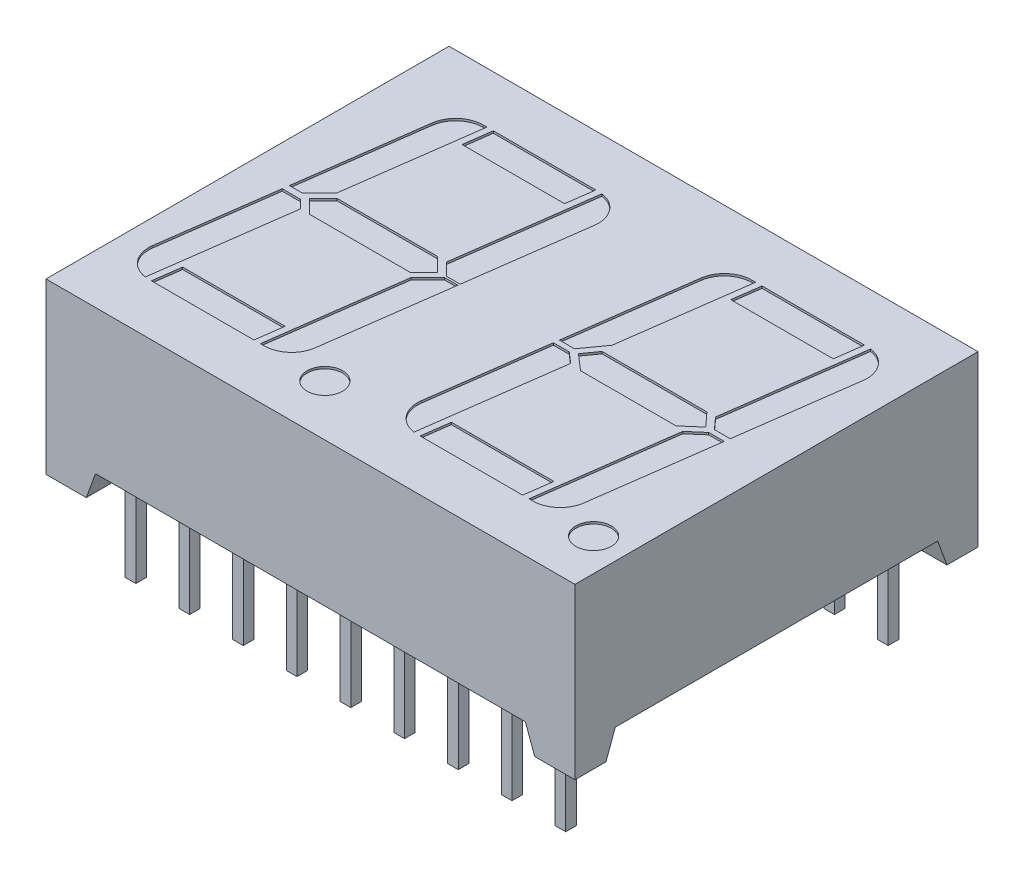
from build123d import *

# Parameters (mm, degrees)
SKETCH1_W          = 25
SKETCH1_H          = 19.05
EXTRUDE2_DEPTH     = 8
CUT_EXTRUDE2_DEPTH = 20.05
CUT_EXTRUDE3_DEPTH = 26
SKETCH5_W          = 0.5
SKETCH5_H          = 0.5
EXTRUDE3_DEPTH     = 1.2
SKETCH5_5_W        = 0.5
SKETCH5_5_H        = 0.5
EXTRUDE4_DEPTH     = 4
SKETCH1_4_R        = 0.84
CUT_EXTRUDE4_DEPTH = 0.1
SKETCH6_W          = 0.026582279
SKETCH6_H          = 0.025316456
CUT_EXTRUDE5_DEPTH = 0.01


with BuildPart() as part:
    # Sketch1 → Extrude2 (new body)
    with BuildSketch(Plane(origin=(0, 0, 0), x_dir=(1, 0, 0), z_dir=(0, 1, 0))):
        Rectangle(SKETCH1_W, SKETCH1_H)
    extrude(amount=-EXTRUDE2_DEPTH)

    # Sketch2 → Cut-Extrude2 (cut, through all)
    with BuildSketch(Plane.XY.offset(9.525)):
        Polygon((-10.596764281, -8), (-10.16, -6.8), (10.16, -6.8), (10.596764281, -8), align=None)
    extrude(amount=-CUT_EXTRUDE2_DEPTH, mode=Mode.SUBTRACT)

    # Sketch3 → Cut-Extrude3 (cut, through all)
    with BuildSketch(Plane(origin=(12.5, 0, 0), x_dir=(0, 0, -1), z_dir=(1, 0, 0))):
        Polygon((-8.056764281, -8), (-7.62, -6.8), (7.62, -6.8), (8.056764281, -8), align=None)
    extrude(amount=-CUT_EXTRUDE3_DEPTH, mode=Mode.SUBTRACT)

    # Sketch5 → Extrude3 (add)
    with BuildSketch(Plane.XZ.offset(8)):
        with Locations((-10.16, 7.62)):
            Rectangle(SKETCH5_W, SKETCH5_H)
        with Locations((-7.62, 7.62)):
            Rectangle(SKETCH5_W, SKETCH5_H)
        with Locations((-5.08, 7.62)):
            Rectangle(SKETCH5_W, SKETCH5_H)
        with Locations((-2.54, 7.62)):
            Rectangle(SKETCH5_W, SKETCH5_H)
        with Locations((0, 7.62)):
            Rectangle(SKETCH5_W, SKETCH5_H)
        with Locations((2.54, 7.62)):
            Rectangle(SKETCH5_W, SKETCH5_H)
        with Locations((7.62, 7.62)):
            Rectangle(SKETCH5_W, SKETCH5_H)
        with Locations((10.16, -7.62)):
            Rectangle(SKETCH5_W, SKETCH5_H)
        with Locations((7.62, -7.62)):
            Rectangle(SKETCH5_W, SKETCH5_H)
        with Locations((5.08, -7.62)):
            Rectangle(SKETCH5_W, SKETCH5_H)
        with Locations((2.54, -7.62)):
            Rectangle(SKETCH5_W, SKETCH5_H)
        with Locations((0, -7.62)):
            Rectangle(SKETCH5_W, SKETCH5_H)
        with Locations((-2.54, -7.62)):
            Rectangle(SKETCH5_W, SKETCH5_H)
        with Locations((-5.08, -7.62)):
            Rectangle(SKETCH5_W, SKETCH5_H)
        with Locations((-7.62, -7.62)):
            Rectangle(SKETCH5_W, SKETCH5_H)
        with Locations((-10.16, -7.62)):
            Rectangle(SKETCH5_W, SKETCH5_H)
        with Locations((5.08, 7.62)):
            Rectangle(SKETCH5_W, SKETCH5_H)
        with Locations((10.16, 7.62)):
            Rectangle(SKETCH5_W, SKETCH5_H)
    extrude(amount=-EXTRUDE3_DEPTH)

    # Sketch5_5 → Extrude4 (add)
    with BuildSketch(Plane.XZ.offset(8)):
        with Locations((-10.16, -7.62)):
            Rectangle(SKETCH5_5_W, SKETCH5_5_H)
        with Locations((-7.62, -7.62)):
            Rectangle(SKETCH5_5_W, SKETCH5_5_H)
        with Locations((-5.08, -7.62)):
            Rectangle(SKETCH5_5_W, SKETCH5_5_H)
        with Locations((-2.54, -7.62)):
            Rectangle(SKETCH5_5_W, SKETCH5_5_H)
        with Locations((0, -7.62)):
            Rectangle(SKETCH5_5_W, SKETCH5_5_H)
        with Locations((2.54, -7.62)):
            Rectangle(SKETCH5_5_W, SKETCH5_5_H)
        with Locations((5.08, -7.62)):
            Rectangle(SKETCH5_5_W, SKETCH5_5_H)
        with Locations((7.62, -7.62)):
            Rectangle(SKETCH5_5_W, SKETCH5_5_H)
        with Locations((10.16, -7.62)):
            Rectangle(SKETCH5_5_W, SKETCH5_5_H)
        with Locations((10.16, 7.62)):
            Rectangle(SKETCH5_5_W, SKETCH5_5_H)
        with Locations((7.62, 7.62)):
            Rectangle(SKETCH5_5_W, SKETCH5_5_H)
        with Locations((5.08, 7.62)):
            Rectangle(SKETCH5_5_W, SKETCH5_5_H)
        with Locations((2.54, 7.62)):
            Rectangle(SKETCH5_5_W, SKETCH5_5_H)
        with Locations((0, 7.62)):
            Rectangle(SKETCH5_5_W, SKETCH5_5_H)
        with Locations((-2.54, 7.62)):
            Rectangle(SKETCH5_5_W, SKETCH5_5_H)
        with Locations((-5.08, 7.62)):
            Rectangle(SKETCH5_5_W, SKETCH5_5_H)
        with Locations((-7.62, 7.62)):
            Rectangle(SKETCH5_5_W, SKETCH5_5_H)
        with Locations((-10.16, 7.62)):
            Rectangle(SKETCH5_5_W, SKETCH5_5_H)
    extrude(amount=EXTRUDE4_DEPTH)

    # Sketch1_4 → Cut-Extrude4 (cut)
    with BuildSketch(Plane(origin=(0, 0, 0), x_dir=(1, 0, 0), z_dir=(0, 1, 0))):
        with BuildLine():
            Line((-3.93123169, -0.847816945), (-4.785666695, -7.11))
            Line((-4.785666695, -7.11), (-4.608289973, -7.11))
            ThreePointArc((-4.608289973, -7.11), (-3.753442858, -6.789406152), (-3.320224553, -5.985748325))
            Line((-3.320224553, -5.985748325), (-2.510329488, -0.05))
            Line((-2.510329488, -0.05), (-3.139803689, -0.05))
            Line((-3.139803689, -0.05), (-3.93123169, -0.847816945))
        make_face()
        Polygon((-5.088446347, -7.11), (-4.911069625, -5.81), (-9.755544062, -5.81), (-9.932920784, -7.11), align=None)
        Polygon((-4.157567593, -0.65), (-3.512772814, 0), (-4.168020055, 0.65), (-8.923571081, 0.65), (-9.56836586, 0), (-8.913118619, -0.65), align=None)
        with BuildLine():
            Line((-10.234072039, -7.09806542), (-9.352465365, -0.63674028))
            Line((-9.352465365, -0.63674028), (-9.742327675, -0.25))
            Line((-9.742327675, -0.25), (-10.611742276, -0.25))
            Line((-10.611742276, -0.25), (-11.346389134, -5.634251675))
            ThreePointArc((-11.346389134, -5.634251675), (-11.093396339, -6.596526961), (-10.234072039, -7.09806542))
        make_face()
        with BuildLine():
            Line((-3.728673309, 0.63674028), (-3.137196463, 0.05))
            Line((-3.137196463, 0.05), (-2.496685125, 0.05))
            Line((-2.496685125, 0.05), (-1.73474954, 5.634251675))
            ThreePointArc((-1.73474954, 5.634251675), (-1.987742335, 6.596526961), (-2.847066635, 7.09806542))
            Line((-2.847066635, 7.09806542), (-3.728673309, 0.63674028))
        make_face()
        with BuildLine():
            Line((-10.570809186, 0.05), (-9.941334985, 0.05))
            Line((-9.941334985, 0.05), (-9.149906984, 0.847816945))
            Line((-9.149906984, 0.847816945), (-8.295471979, 7.11))
            Line((-8.295471979, 7.11), (-8.472848701, 7.11))
            ThreePointArc((-8.472848701, 7.11), (-9.327695816, 6.789406152), (-9.760914121, 5.985748325))
            Line((-9.760914121, 5.985748325), (-10.570809186, 0.05))
        make_face()
        Polygon((-8.170069049, 5.81), (-3.325594612, 5.81), (-3.14821789, 7.11), (-7.992692327, 7.11), align=None)
        Polygon((7.789032999, -5.81), (2.944558562, -5.81), (2.76718184, -7.11), (7.611656276, -7.11), align=None)
        with BuildLine():
            Line((2.466030585, -7.09806542), (3.35486626, -0.583758689))
            Line((3.35486626, -0.583758689), (2.851674798, -0.145974081))
            Line((2.851674798, -0.145974081), (2.102554022, -0.145974081))
            Line((2.102554022, -0.145974081), (1.35371349, -5.634251675))
            ThreePointArc((1.35371349, -5.634251675), (1.606706284, -6.596526961), (2.466030585, -7.09806542))
        make_face()
        with BuildLine():
            Line((8.787000175, -0.714947122), (7.914435929, -7.11))
            Line((7.914435929, -7.11), (8.091812651, -7.11))
            ThreePointArc((8.091812651, -7.11), (8.946659765, -6.789406152), (9.379878071, -5.985748325))
            Line((9.379878071, -5.985748325), (10.176678083, -0.145974081))
            Line((10.176678083, -0.145974081), (9.444259288, -0.145974081))
            Line((9.444259288, -0.145974081), (8.787000175, -0.714947122))
        make_face()
        Polygon((3.888061955, -0.65), (8.403661518, -0.65), (9.154520334, 0), (8.563273677, 0.65), (3.608753705, 0.65), (3.140949231, 0), align=None)
        with BuildLine():
            Line((2.136936451, 0.106015903), (2.84763139, 0.106015903))
            Line((2.84763139, 0.106015903), (3.589658211, 1.137039464))
            Line((3.589658211, 1.137039464), (4.404630645, 7.11))
            Line((4.404630645, 7.11), (4.227253922, 7.11))
            ThreePointArc((4.227253922, 7.11), (3.372406808, 6.789406152), (2.939188502, 5.985748325))
            Line((2.939188502, 5.985748325), (2.136936451, 0.106015903))
        make_face()
        with BuildLine():
            Line((8.972661757, 0.64577289), (9.46363024, 0.106015903))
            Line((9.46363024, 0.106015903), (10.211060512, 0.106015903))
            Line((10.211060512, 0.106015903), (10.965353084, 5.634251675))
            ThreePointArc((10.965353084, 5.634251675), (10.712360289, 6.59652696), (9.853035989, 7.09806542))
            Line((9.853035989, 7.09806542), (8.972661757, 0.64577289))
        make_face()
        Polygon((4.707410297, 7.11), (4.530033575, 5.81), (9.374508011, 5.81), (9.551884734, 7.11), align=None)
        with Locations(Location((-1.73474954, -7.11, 0), (0, 0, 90))):  # turned: the seam where the file's is
            Circle(SKETCH1_4_R)
        with Locations(Location((10.965353084, -7.11, 0), (0, 0, 90))):  # turned: the seam where the file's is
            Circle(SKETCH1_4_R)
    extrude(amount=-CUT_EXTRUDE4_DEPTH, mode=Mode.SUBTRACT)

    # Sketch6 → Cut-Extrude5 (cut)
    with BuildSketch(Plane.XZ.offset(6.8)):
        Polygon((-10.77177609, 0.348226109), (-10.846459634, 0.371683388), (-10.846459634, 0.396426268), (-10.7961234, 0.412842407), (-10.846459634, 0.428368514), (-10.846459634, 0.454100318), (-10.77177609, 0.477340033), (-10.77177609, 0.452162027), (-10.823259476, 0.439167565), (-10.77177609, 0.422751426), (-10.77177609, 0.401252217), (-10.823259476, 0.38493497), (-10.77177609, 0.372118514), align=None)
        Polygon((-10.77177609, 0.214048894), (-10.846459634, 0.237506173), (-10.846459634, 0.262249052), (-10.7961234, 0.278665192), (-10.846459634, 0.294191299), (-10.846459634, 0.319923103), (-10.77177609, 0.343162818), (-10.77177609, 0.317984812), (-10.823259476, 0.30499035), (-10.77177609, 0.288574211), (-10.77177609, 0.267075002), (-10.823259476, 0.250757755), (-10.77177609, 0.237941299), align=None)
        Polygon((-10.77177609, 0.079871679), (-10.846459634, 0.103328957), (-10.846459634, 0.128071837), (-10.7961234, 0.144487976), (-10.846459634, 0.160014084), (-10.846459634, 0.185745888), (-10.77177609, 0.208985603), (-10.77177609, 0.183807597), (-10.823259476, 0.170813135), (-10.77177609, 0.154396995), (-10.77177609, 0.132897787), (-10.823259476, 0.11658054), (-10.77177609, 0.103764084), align=None)
        with Locations((-10.833168495, 0.052023578)):
            Rectangle(SKETCH6_W, SKETCH6_H)
        with BuildLine():
            add(Edge.make_bspline(
                [(-10.815288748, -0.064432118), (-10.816510881, -0.06439562), (-10.818910744, -0.06432395), (-10.822418432, -0.063714363), (-10.825742736, -0.062720396), (-10.828906881, -0.061348057), (-10.83187637, -0.059554601), (-10.834679261, -0.05737133), (-10.837283806, -0.054782447), (-10.83972018, -0.051835643), (-10.841902292, -0.0485387), (-10.843808325, -0.044940986), (-10.845402996, -0.041060959), (-10.846742062, -0.036912748), (-10.847730495, -0.032466201), (-10.848454482, -0.027748703), (-10.8489278, -0.022755275), (-10.848969768, -0.019331698), (-10.848991279, -0.017576897)],
                knots=[0, 0, 0, 0, 0.907312236, 1.78165839, 2.635367075, 3.479697475, 4.336364812, 5.205276731, 6.11257575, 7.058770404, 8.040786331, 9.044147278, 10.078219212, 11.153049307, 12.278104542, 13.457648573, 14.696882856, 16, 16, 16, 16], degree=3))
            add(Edge.make_bspline(
                [(-10.848991279, -0.017576897), (-10.848967208, -0.015558642), (-10.848920583, -0.011649459), (-10.848491984, -0.005985934), (-10.847845844, -0.000717897), (-10.846879303, 0.004177818), (-10.845678538, 0.008782417), (-10.844387246, 0.013215685), (-10.84292283, 0.017496997), (-10.841822673, 0.020270086), (-10.841277672, 0.021643831)],
                knots=[0, 0, 0, 0, 1.203215828, 2.33052265, 3.384689099, 4.366106119, 5.303329643, 6.221311756, 7.118865988, 8, 8, 8, 8], degree=3))
            Line((-10.841277672, 0.021643831), (-10.81734571, 0.021643831))
            Line((-10.81734571, 0.021643831), (-10.81734571, 0.01879573))
            add(Edge.make_bspline(
                [(-10.81734571, 0.01879573), (-10.818427165, 0.017430416), (-10.820583726, 0.014707803), (-10.823346331, 0.01027457), (-10.825748494, 0.005626924), (-10.827722496, 0.000781453), (-10.82930882, -0.004115391), (-10.830402347, -0.008990769), (-10.831149696, -0.013756356), (-10.831230203, -0.016914926), (-10.83126976, -0.018466929)],
                knots=[0, 0, 0, 0, 1.030622468, 2.055194264, 3.087043286, 4.125157485, 5.149848264, 6.130935704, 7.081611712, 8, 8, 8, 8], degree=3))
            add(Edge.make_bspline(
                [(-10.83126976, -0.018466929), (-10.831268866, -0.018895707), (-10.831266951, -0.019813689), (-10.831138108, -0.021281726), (-10.831044944, -0.022940325), (-10.830835727, -0.024719191), (-10.830617144, -0.026510009), (-10.830236823, -0.028164669), (-10.829874985, -0.029668308), (-10.829506807, -0.03057479), (-10.829331469, -0.031006486)],
                knots=[0, 0, 0, 0, 0.806378557, 1.726393851, 2.771014456, 3.931269413, 5.096090628, 6.161710732, 7.124547685, 8, 8, 8, 8], degree=3))
            add(Edge.make_bspline(
                [(-10.829331469, -0.031006486), (-10.829103646, -0.031486272), (-10.828655923, -0.032429156), (-10.827838317, -0.033724075), (-10.826967015, -0.034906747), (-10.826001596, -0.035968208), (-10.824823687, -0.036818475), (-10.823422831, -0.037446676), (-10.821772531, -0.03778977), (-10.82059752, -0.037829064), (-10.819976248, -0.03784984)],
                knots=[0, 0, 0, 0, 1.024407818, 2.013179384, 2.949802342, 3.859052226, 4.77034807, 5.732977883, 6.801339628, 8, 8, 8, 8], degree=3))
            add(Edge.make_bspline(
                [(-10.819976248, -0.03784984), (-10.819430352, -0.037818398), (-10.818356959, -0.037756575), (-10.816828963, -0.037174783), (-10.815407086, -0.036291885), (-10.814146371, -0.035004862), (-10.812988932, -0.033410786), (-10.812018635, -0.031455049), (-10.811138562, -0.02920207), (-10.810721293, -0.027557611), (-10.810502355, -0.026694777)],
                knots=[0, 0, 0, 0, 0.825212765, 1.622611382, 2.449701629, 3.348069183, 4.336544339, 5.428209675, 6.6506027, 8, 8, 8, 8], degree=3))
            add(Edge.make_bspline(
                [(-10.810502355, -0.026694777), (-10.810054615, -0.02472605), (-10.809137425, -0.020693142), (-10.807990318, -0.014545033), (-10.806724245, -0.008414805), (-10.805514704, -0.004456093), (-10.804924824, -0.002525473)],
                knots=[0, 0, 0, 0, 0.976104583, 1.999535498, 3.024395274, 4, 4, 4, 4], degree=3))
            add(Edge.make_bspline(
                [(-10.804924824, -0.002525473), (-10.804571831, -0.001486957), (-10.803884698, 0.000534611), (-10.802723073, 0.003426155), (-10.801453121, 0.006087268), (-10.800097989, 0.008527378), (-10.798623991, 0.0107267), (-10.797090602, 0.01272189), (-10.795436765, 0.014465416), (-10.793704845, 0.0160131), (-10.791852843, 0.017336414), (-10.789908706, 0.018491164), (-10.787848241, 0.0194668), (-10.785686952, 0.020275683), (-10.783408083, 0.020892756), (-10.78103121, 0.021314012), (-10.77854785, 0.021612401), (-10.776853497, 0.021633212), (-10.775988906, 0.021643831)],
                knots=[0, 0, 0, 0, 1.287286806, 2.505824366, 3.654938963, 4.74627059, 5.778586806, 6.75996495, 7.696030012, 8.595059759, 9.482019644, 10.363222407, 11.245851011, 12.154256429, 13.068444161, 14.012503255, 14.985824751, 16, 16, 16, 16], degree=3))
            add(Edge.make_bspline(
                [(-10.775988906, 0.021643831), (-10.774832761, 0.021606529), (-10.772557489, 0.02153312), (-10.769228445, 0.020931691), (-10.766079708, 0.019905101), (-10.763076245, 0.018519037), (-10.760263159, 0.016690409), (-10.757584612, 0.014505615), (-10.75511302, 0.011881567), (-10.752812686, 0.008904446), (-10.750733288, 0.005617062), (-10.748902731, 0.002078078), (-10.74736608, -0.001691211), (-10.746092186, -0.005676758), (-10.745137515, -0.009895227), (-10.744418583, -0.014332459), (-10.744005402, -0.019006248), (-10.743954152, -0.02219767), (-10.743927988, -0.023826897)],
                knots=[0, 0, 0, 0, 0.894990994, 1.761326291, 2.609044902, 3.454222546, 4.315366365, 5.200560057, 6.125081389, 7.100429509, 8.110379559, 9.133447974, 10.182136699, 11.259192205, 12.370181258, 13.528580438, 14.738335141, 16, 16, 16, 16], degree=3))
            add(Edge.make_bspline(
                [(-10.743927988, -0.023826897), (-10.74395018, -0.025495584), (-10.743994525, -0.028830129), (-10.744372503, -0.033811571), (-10.744927731, -0.038772073), (-10.745769437, -0.043635904), (-10.746745854, -0.048326459), (-10.747841649, -0.052739695), (-10.749079613, -0.056819155), (-10.750033958, -0.059392819), (-10.750494444, -0.06063465)],
                knots=[0, 0, 0, 0, 1.065403572, 2.129000689, 3.188532477, 4.251604565, 5.279552602, 6.247508681, 7.154397237, 8, 8, 8, 8], degree=3))
            Line((-10.750494444, -0.06063465), (-10.773041912, -0.06063465))
            Line((-10.773041912, -0.06063465), (-10.773041912, -0.057806327))
            add(Edge.make_bspline(
                [(-10.773041912, -0.057806327), (-10.772241566, -0.056733423), (-10.770604836, -0.054539304), (-10.768521163, -0.050879667), (-10.766563298, -0.046921432), (-10.764879139, -0.042642601), (-10.763419658, -0.038183574), (-10.762400492, -0.033600615), (-10.761758682, -0.028974451), (-10.761685907, -0.02587274), (-10.761649507, -0.024321359)],
                knots=[0, 0, 0, 0, 0.892283326, 1.824742884, 2.804416662, 3.836872171, 4.8899239, 5.931447339, 6.965372909, 8, 8, 8, 8], degree=3))
            add(Edge.make_bspline(
                [(-10.761649507, -0.024321359), (-10.76167096, -0.023225691), (-10.761713862, -0.021034475), (-10.762104546, -0.017766266), (-10.76273544, -0.014524205), (-10.763554722, -0.012483683), (-10.76396359, -0.011465346)],
                knots=[0, 0, 0, 0, 0.999146175, 1.998183711, 3.000980573, 4, 4, 4, 4], degree=3))
            add(Edge.make_bspline(
                [(-10.76396359, -0.011465346), (-10.764165056, -0.011031843), (-10.764567856, -0.010165126), (-10.765340419, -0.008958481), (-10.76626923, -0.007853812), (-10.767321223, -0.006861735), (-10.768477596, -0.005993337), (-10.769752422, -0.005377986), (-10.771115337, -0.005002113), (-10.772050568, -0.004959955), (-10.772527672, -0.004938448)],
                knots=[0, 0, 0, 0, 1.00524851, 2.009826503, 3.004679593, 4.035271301, 5.048246368, 6.034938417, 6.997532266, 8, 8, 8, 8], degree=3))
            add(Edge.make_bspline(
                [(-10.772527672, -0.004938448), (-10.773165837, -0.004972886), (-10.774385313, -0.005038694), (-10.776101109, -0.005645278), (-10.777579543, -0.006630112), (-10.778574463, -0.007790716), (-10.779271901, -0.008907846), (-10.779782411, -0.009943506), (-10.78026577, -0.011152733), (-10.780763239, -0.01252398), (-10.781254426, -0.014060307), (-10.781729973, -0.015768864), (-10.782179269, -0.017651581), (-10.782465459, -0.018967456), (-10.782614697, -0.019653637)],
                knots=[0, 0, 0, 0, 1.173816843, 2.243057204, 3.312297565, 4.415174738, 5.03266065, 5.73970059, 6.541434878, 7.433956553, 8.430083051, 9.515931566, 10.70464786, 12, 12, 12, 12], degree=3))
            add(Edge.make_bspline(
                [(-10.782614697, -0.019653637), (-10.782990759, -0.021486427), (-10.783729636, -0.025087453), (-10.784833125, -0.030488636), (-10.786108094, -0.03599141), (-10.787256897, -0.039656736), (-10.787855995, -0.041568194)],
                knots=[0, 0, 0, 0, 0.995744513, 1.956417928, 2.934277412, 4, 4, 4, 4], degree=3))
            add(Edge.make_bspline(
                [(-10.787855995, -0.041568194), (-10.788175239, -0.042514749), (-10.788799731, -0.044366362), (-10.789886014, -0.047006992), (-10.791059997, -0.049454051), (-10.792301528, -0.051721084), (-10.793645494, -0.053795054), (-10.795068141, -0.055689736), (-10.79659505, -0.057373554), (-10.798208277, -0.05887112), (-10.799918378, -0.06019028), (-10.80175745, -0.061322578), (-10.803706253, -0.062294806), (-10.805792453, -0.063064411), (-10.80798704, -0.063682431), (-10.810318408, -0.064105528), (-10.812762784, -0.064399512), (-10.814437361, -0.064421128), (-10.815288748, -0.064432118)],
                knots=[0, 0, 0, 0, 1.237467875, 2.420686895, 3.535046182, 4.599015201, 5.620884487, 6.594603852, 7.531477383, 8.433220087, 9.318759595, 10.202828513, 11.105163009, 12.01247538, 12.953896178, 13.926381251, 14.945733412, 16, 16, 16, 16], degree=3))
        make_face()
        with BuildLine():
            Line((-10.846459634, -0.156837182), (-10.846459634, -0.132786549))
            Line((-10.846459634, -0.132786549), (-10.838627355, -0.132786549))
            add(Edge.make_bspline(
                [(-10.838627355, -0.132786549), (-10.839435914, -0.13169324), (-10.840994802, -0.129585357), (-10.84307502, -0.126412332), (-10.844850286, -0.123386241), (-10.846409506, -0.120472751), (-10.847584892, -0.117450547), (-10.848412958, -0.114219033), (-10.848912731, -0.110716208), (-10.848964515, -0.108289314), (-10.848991279, -0.107034967)],
                knots=[0, 0, 0, 0, 1.150872466, 2.218865267, 3.209461834, 4.120482262, 5.012764827, 5.946708227, 6.938749913, 8, 8, 8, 8], degree=3))
            add(Edge.make_bspline(
                [(-10.848991279, -0.107034967), (-10.84896856, -0.106018615), (-10.84892432, -0.104039484), (-10.848579442, -0.101162244), (-10.848041791, -0.098454616), (-10.8472342, -0.095939576), (-10.846268397, -0.093575587), (-10.844988439, -0.091438037), (-10.843558265, -0.089434436), (-10.841851219, -0.087652763), (-10.839953486, -0.086037142), (-10.837821025, -0.084654592), (-10.8354881, -0.083476881), (-10.832936246, -0.082535783), (-10.830177943, -0.081780694), (-10.827198695, -0.081256761), (-10.824011568, -0.080936169), (-10.821816437, -0.080904229), (-10.820688273, -0.080887815)],
                knots=[0, 0, 0, 0, 1.109008058, 2.159558935, 3.158726032, 4.116861086, 5.039058877, 5.938775559, 6.82970133, 7.720510853, 8.624361809, 9.544451588, 10.487360536, 11.471068125, 12.508000841, 13.604731202, 14.768976642, 16, 16, 16, 16], degree=3))
            Line((-10.820688273, -0.080887815), (-10.77177609, -0.080887815))
            Line((-10.77177609, -0.080887815), (-10.77177609, -0.104938448))
            Line((-10.77177609, -0.104938448), (-10.809355203, -0.104938448))
            add(Edge.make_bspline(
                [(-10.809355203, -0.104938448), (-10.810271674, -0.104940083), (-10.81202589, -0.104943214), (-10.814531697, -0.105025553), (-10.816799869, -0.105146453), (-10.818841898, -0.105285158), (-10.820688648, -0.105538175), (-10.82235481, -0.105915883), (-10.823874411, -0.106386709), (-10.824781113, -0.106851028), (-10.825217545, -0.107074524)],
                knots=[0, 0, 0, 0, 1.361401701, 2.605856924, 3.723918663, 4.735739235, 5.645738665, 6.489217889, 7.27279937, 8, 8, 8, 8], degree=3))
            add(Edge.make_bspline(
                [(-10.825217545, -0.107074524), (-10.82561626, -0.10730453), (-10.826400099, -0.107756704), (-10.827406278, -0.108676994), (-10.828250545, -0.109755736), (-10.828906574, -0.11103334), (-10.829405522, -0.112519888), (-10.829745759, -0.114247819), (-10.829961261, -0.116233181), (-10.829989169, -0.117642199), (-10.830003938, -0.118387815)],
                knots=[0, 0, 0, 0, 0.849138082, 1.669332372, 2.503455908, 3.370611167, 4.311442699, 5.394692208, 6.621337967, 8, 8, 8, 8], degree=3))
            add(Edge.make_bspline(
                [(-10.830003938, -0.118387815), (-10.829986581, -0.118929099), (-10.829950893, -0.120042016), (-10.829718447, -0.121753329), (-10.829361773, -0.123549906), (-10.828701917, -0.126064488), (-10.827515738, -0.129231116), (-10.82616133, -0.131590417), (-10.825474665, -0.132786549)],
                knots=[0, 0, 0, 0, 0.638127216, 1.312033637, 2.033062677, 2.79661882, 4.375931797, 6, 6, 6, 6], degree=3))
            Line((-10.825474665, -0.132786549), (-10.77177609, -0.132786549))
            Line((-10.77177609, -0.132786549), (-10.77177609, -0.156837182))
            Line((-10.77177609, -0.156837182), (-10.846459634, -0.156837182))
        make_face()
        with BuildLine():
            Line((-10.846459634, -0.254305536), (-10.846459634, -0.230254903))
            Line((-10.846459634, -0.230254903), (-10.80888052, -0.230254903))
            add(Edge.make_bspline(
                [(-10.80888052, -0.230254903), (-10.807350477, -0.230230389), (-10.804299452, -0.230181505), (-10.800537041, -0.229899381), (-10.797694717, -0.229520859), (-10.795856836, -0.229151204), (-10.794308696, -0.228719504), (-10.793422937, -0.228307224), (-10.793018178, -0.228118827)],
                knots=[0, 0, 0, 0, 1.709124929, 3.408128882, 4.211124727, 4.91016634, 5.501986363, 6, 6, 6, 6], degree=3))
            add(Edge.make_bspline(
                [(-10.793018178, -0.228118827), (-10.792620125, -0.227874365), (-10.791839685, -0.227395061), (-10.790826672, -0.226457737), (-10.789997831, -0.225363851), (-10.78931628, -0.224093081), (-10.7888457, -0.222601884), (-10.78845247, -0.220885144), (-10.788285561, -0.218898526), (-10.788250401, -0.217491256), (-10.788231786, -0.216746201)],
                knots=[0, 0, 0, 0, 0.86006424, 1.686277094, 2.52783008, 3.38194165, 4.331801563, 5.402842185, 6.624978739, 8, 8, 8, 8], degree=3))
            add(Edge.make_bspline(
                [(-10.788231786, -0.216746201), (-10.788288523, -0.215614379), (-10.788404376, -0.213303285), (-10.789115884, -0.210441091), (-10.789934843, -0.208110487), (-10.790693674, -0.206257963), (-10.791665116, -0.204349332), (-10.792386938, -0.20306992), (-10.792761058, -0.202406802)],
                knots=[0, 0, 0, 0, 1.338371478, 2.732853438, 3.468019217, 4.261884641, 5.099136535, 6, 6, 6, 6], degree=3))
            Line((-10.792761058, -0.202406802), (-10.846459634, -0.202406802))
            Line((-10.846459634, -0.202406802), (-10.846459634, -0.178356169))
            Line((-10.846459634, -0.178356169), (-10.77177609, -0.178356169))
            Line((-10.77177609, -0.178356169), (-10.77177609, -0.202406802))
            Line((-10.77177609, -0.202406802), (-10.779608368, -0.202406802))
            add(Edge.make_bspline(
                [(-10.779608368, -0.202406802), (-10.778802216, -0.203464209), (-10.777232994, -0.205522513), (-10.775192574, -0.208701751), (-10.773393804, -0.211785649), (-10.771880988, -0.214838659), (-10.770674213, -0.217953614), (-10.769863224, -0.221216372), (-10.769319421, -0.224632778), (-10.769269727, -0.226969493), (-10.769244444, -0.228158384)],
                knots=[0, 0, 0, 0, 1.126119141, 2.192057864, 3.198061997, 4.149848529, 5.076251285, 6.021887753, 6.99356175, 8, 8, 8, 8], degree=3))
            add(Edge.make_bspline(
                [(-10.769244444, -0.228158384), (-10.769269833, -0.229154656), (-10.769319397, -0.231099555), (-10.769629106, -0.233934315), (-10.770179771, -0.236605736), (-10.7709776, -0.23909801), (-10.771963212, -0.24144063), (-10.773194727, -0.243602574), (-10.77465315, -0.245594645), (-10.776314153, -0.247423046), (-10.778203879, -0.249053864), (-10.780321143, -0.2504709), (-10.78266424, -0.251650882), (-10.785224549, -0.252621594), (-10.787989658, -0.253396017), (-10.790985624, -0.253911148), (-10.794189802, -0.254264932), (-10.796405846, -0.254291731), (-10.79754745, -0.254305536)],
                knots=[0, 0, 0, 0, 1.08848837, 2.124922927, 3.110950502, 4.063144162, 4.979605775, 5.882838355, 6.774625441, 7.671951181, 8.57587277, 9.494821853, 10.448322275, 11.435533005, 12.482327682, 13.580118324, 14.753386918, 16, 16, 16, 16], degree=3))
            Line((-10.79754745, -0.254305536), (-10.846459634, -0.254305536))
        make_face()
        Polygon((-10.846459634, -0.349242245), (-10.846459634, -0.277090346), (-10.746459634, -0.277090346), (-10.746459634, -0.302406802), (-10.827472292, -0.302406802), (-10.827472292, -0.349242245), align=None)
        Polygon((-10.846459634, -0.436584017), (-10.846459634, -0.364432118), (-10.746459634, -0.364432118), (-10.746459634, -0.436584017), (-10.765446976, -0.436584017), (-10.765446976, -0.389748574), (-10.783168495, -0.389748574), (-10.783168495, -0.432786549), (-10.802155836, -0.432786549), (-10.802155836, -0.389748574), (-10.827472292, -0.389748574), (-10.827472292, -0.436584017), align=None)
        with BuildLine():
            add(Edge.make_bspline(
                [(-10.796558526, -0.553039713), (-10.797706215, -0.553020398), (-10.799979101, -0.552982146), (-10.803343908, -0.552686955), (-10.806609583, -0.552160929), (-10.809793832, -0.551481748), (-10.812872759, -0.550559242), (-10.815880337, -0.549477528), (-10.81878583, -0.548167882), (-10.821587265, -0.54666303), (-10.824259367, -0.545013558), (-10.826779576, -0.543238809), (-10.829162794, -0.541393029), (-10.831357688, -0.539403717), (-10.833399707, -0.537324535), (-10.835290522, -0.535149007), (-10.836993952, -0.532843942), (-10.838016837, -0.53123678), (-10.838528463, -0.53043291)],
                knots=[0, 0, 0, 0, 1.105570398, 2.18947457, 3.250358341, 4.290584537, 5.323553275, 6.344225964, 7.367641686, 8.3905646, 9.405808457, 10.390761353, 11.358902336, 12.307789878, 13.241960776, 14.165076779, 15.082208636, 16, 16, 16, 16], degree=3))
            add(Edge.make_bspline(
                [(-10.838528463, -0.53043291), (-10.839240602, -0.529193681), (-10.840668515, -0.526708902), (-10.842337105, -0.522725067), (-10.843741221, -0.518599585), (-10.844795646, -0.514249198), (-10.84552269, -0.509602189), (-10.846083496, -0.50460078), (-10.846385256, -0.49919319), (-10.846434276, -0.495458295), (-10.846459634, -0.493526264)],
                knots=[0, 0, 0, 0, 0.896288622, 1.797150563, 2.705281913, 3.629615989, 4.602417572, 5.655716007, 6.787320449, 8, 8, 8, 8], degree=3))
            Line((-10.846459634, -0.493526264), (-10.846459634, -0.458103005))
            Line((-10.846459634, -0.458103005), (-10.746459634, -0.458103005))
            Line((-10.746459634, -0.458103005), (-10.746459634, -0.494534967))
            add(Edge.make_bspline(
                [(-10.746459634, -0.494534967), (-10.746476245, -0.496513698), (-10.746508285, -0.500330427), (-10.746925876, -0.505847266), (-10.7475227, -0.510952474), (-10.748447571, -0.515637822), (-10.749562916, -0.519937826), (-10.750922044, -0.523863302), (-10.752420752, -0.527475076), (-10.753694445, -0.529653918), (-10.754311691, -0.530709808)],
                knots=[0, 0, 0, 0, 1.267175336, 2.444223962, 3.542125549, 4.557526608, 5.500936977, 6.385043188, 7.217374394, 8, 8, 8, 8], degree=3))
            add(Edge.make_bspline(
                [(-10.754311691, -0.530709808), (-10.754848231, -0.531560762), (-10.755915145, -0.533252886), (-10.757696997, -0.535654101), (-10.759653074, -0.537883528), (-10.761704893, -0.540012031), (-10.76390778, -0.541991849), (-10.766246487, -0.543835048), (-10.768724581, -0.545538865), (-10.77133405, -0.547096829), (-10.774064102, -0.548517644), (-10.776937161, -0.54970695), (-10.779915691, -0.550756299), (-10.783024653, -0.551561835), (-10.78623249, -0.552259749), (-10.789573834, -0.552694484), (-10.793026322, -0.552981095), (-10.795371212, -0.553020009), (-10.796558526, -0.553039713)],
                knots=[0, 0, 0, 0, 0.964065863, 1.917049184, 2.86229036, 3.805247319, 4.749389377, 5.698846072, 6.657678277, 7.629829384, 8.610569287, 9.604676042, 10.607940105, 11.6349849, 12.681042988, 13.752616828, 14.862056989, 16, 16, 16, 16], degree=3))
        make_face()
        with BuildLine():
            add(Edge.make_bspline(
                [(-10.796400298, -0.526457435), (-10.795595538, -0.526447194), (-10.794016954, -0.526427107), (-10.79170144, -0.526235539), (-10.78947179, -0.525976483), (-10.787337098, -0.525545429), (-10.785277527, -0.525045782), (-10.783320033, -0.524403633), (-10.78144046, -0.523679236), (-10.779662971, -0.522797598), (-10.777954589, -0.521823961), (-10.776369073, -0.520676468), (-10.774856187, -0.51942813), (-10.773428203, -0.518049844), (-10.772122307, -0.516506903), (-10.77089223, -0.514846801), (-10.769763904, -0.513046443), (-10.769103855, -0.511773455), (-10.76876976, -0.511129112)],
                knots=[0, 0, 0, 0, 1.152093354, 2.259898929, 3.325467225, 4.364140538, 5.376172865, 6.358396836, 7.312077728, 8.257828931, 9.196960457, 10.124297759, 11.056236784, 12.004246951, 12.961658638, 13.947279359, 14.960983522, 16, 16, 16, 16], degree=3))
            add(Edge.make_bspline(
                [(-10.76876976, -0.511129112), (-10.768463048, -0.510454214), (-10.767855124, -0.50911652), (-10.767123932, -0.507045697), (-10.766551096, -0.504956314), (-10.766120238, -0.502754714), (-10.765798307, -0.500284955), (-10.765601048, -0.497359373), (-10.765458879, -0.493903464), (-10.765451127, -0.491416749), (-10.765446976, -0.490084808)],
                knots=[0, 0, 0, 0, 0.826967603, 1.639107464, 2.447640171, 3.242670507, 4.14065217, 5.225198036, 6.513753944, 8, 8, 8, 8], degree=3))
            Line((-10.765446976, -0.490084808), (-10.765446976, -0.48341946))
            Line((-10.765446976, -0.48341946), (-10.827472292, -0.48341946))
            Line((-10.827472292, -0.48341946), (-10.827472292, -0.490084808))
            add(Edge.make_bspline(
                [(-10.827472292, -0.490084808), (-10.827467542, -0.490843015), (-10.827458373, -0.492306781), (-10.827415311, -0.494423024), (-10.827368423, -0.496388821), (-10.827251961, -0.498193691), (-10.827179315, -0.499852376), (-10.827000936, -0.501339157), (-10.826858756, -0.502681647), (-10.826591033, -0.504249243), (-10.82617485, -0.506102409), (-10.825496671, -0.508263669), (-10.824646276, -0.510404204), (-10.823961308, -0.511792777), (-10.823615488, -0.512493827)],
                knots=[0, 0, 0, 0, 1.186793418, 2.291178421, 3.313283093, 4.264083014, 5.122158624, 5.910777728, 6.607099052, 7.234812932, 8.398911528, 9.577194775, 10.776795607, 12, 12, 12, 12], degree=3))
            add(Edge.make_bspline(
                [(-10.823615488, -0.512493827), (-10.823273972, -0.513078943), (-10.822600458, -0.514232869), (-10.821466384, -0.515856374), (-10.820258659, -0.517364091), (-10.818970208, -0.518760103), (-10.817581966, -0.520023403), (-10.816115425, -0.521175422), (-10.814567447, -0.522205871), (-10.812373929, -0.52344126), (-10.809342992, -0.524664506), (-10.805375606, -0.525704048), (-10.801015843, -0.52634092), (-10.797978225, -0.526417602), (-10.796400298, -0.526457435)],
                knots=[0, 0, 0, 0, 0.755160452, 1.489275589, 2.205657296, 2.907868421, 3.605098304, 4.296256403, 4.985378686, 5.676536785, 7.100390329, 8.614249252, 10.241231541, 12, 12, 12, 12], degree=3))
        make_face(mode=Mode.SUBTRACT)
        with Locations((-10.833168495, -0.584685283)):
            Rectangle(SKETCH6_W, SKETCH6_H)
        with BuildLine():
            add(Edge.make_bspline(
                [(-10.848991279, -0.65932927), (-10.848969468, -0.657739157), (-10.848926657, -0.654618021), (-10.84844974, -0.650046679), (-10.847732044, -0.645681507), (-10.846711138, -0.641535199), (-10.845363642, -0.637621407), (-10.843710706, -0.63395777), (-10.841725521, -0.630550913), (-10.840146313, -0.628492266), (-10.839359159, -0.627466137)],
                knots=[0, 0, 0, 0, 1.123670284, 2.205584497, 3.245308791, 4.249063313, 5.220352711, 6.167273909, 7.086481357, 8, 8, 8, 8], degree=3))
            add(Edge.make_bspline(
                [(-10.839359159, -0.627466137), (-10.838504385, -0.62651439), (-10.836798142, -0.624614575), (-10.833826715, -0.622148642), (-10.830543671, -0.620025557), (-10.826941449, -0.618240004), (-10.82302472, -0.61680908), (-10.818780057, -0.615785947), (-10.814219277, -0.615166701), (-10.811071343, -0.615099536), (-10.809454096, -0.61506503)],
                knots=[0, 0, 0, 0, 0.916457077, 1.82937027, 2.759194969, 3.714948755, 4.706655623, 5.743329475, 6.840637961, 8, 8, 8, 8], degree=3))
            add(Edge.make_bspline(
                [(-10.809454096, -0.61506503), (-10.807750869, -0.61510379), (-10.804449789, -0.615178913), (-10.799677601, -0.615842673), (-10.79525992, -0.616912285), (-10.791208012, -0.618449843), (-10.787514821, -0.620380285), (-10.784142986, -0.622644778), (-10.781100062, -0.625265304), (-10.779354622, -0.627272442), (-10.778480995, -0.628277055)],
                knots=[0, 0, 0, 0, 1.171797512, 2.271099083, 3.308930235, 4.294129479, 5.24602549, 6.17106565, 7.084581485, 8, 8, 8, 8], degree=3))
            add(Edge.make_bspline(
                [(-10.778480995, -0.628277055), (-10.777712408, -0.629302926), (-10.776165952, -0.631367057), (-10.774265253, -0.634770562), (-10.772670467, -0.638393777), (-10.771422822, -0.642223348), (-10.770468917, -0.646196157), (-10.769745073, -0.650255816), (-10.769324515, -0.654402069), (-10.769271263, -0.657192269), (-10.769244444, -0.658597467)],
                knots=[0, 0, 0, 0, 0.952130878, 1.915761808, 2.890227217, 3.891541892, 4.905612075, 5.925811839, 6.955400088, 8, 8, 8, 8], degree=3))
            add(Edge.make_bspline(
                [(-10.769244444, -0.658597467), (-10.769261446, -0.659844185), (-10.769294878, -0.662295657), (-10.769616988, -0.665896703), (-10.770150107, -0.669351245), (-10.77088871, -0.672656177), (-10.771780312, -0.675830123), (-10.772819454, -0.6788803), (-10.773952722, -0.68184011), (-10.774837257, -0.683740679), (-10.775276881, -0.684685283)],
                knots=[0, 0, 0, 0, 1.107648782, 2.178012834, 3.209595929, 4.211695017, 5.185427128, 6.137685403, 7.07440854, 8, 8, 8, 8], degree=3))
            Line((-10.775276881, -0.684685283), (-10.795826722, -0.684685283))
            Line((-10.795826722, -0.684685283), (-10.795826722, -0.68134272))
            add(Edge.make_bspline(
                [(-10.795826722, -0.68134272), (-10.795409502, -0.680843176), (-10.794507788, -0.67976354), (-10.793087036, -0.677977124), (-10.791557443, -0.675828182), (-10.790665496, -0.674174646), (-10.790189855, -0.673292878)],
                knots=[0, 0, 0, 0, 0.792826818, 1.713491785, 2.780691913, 4, 4, 4, 4], degree=3))
            add(Edge.make_bspline(
                [(-10.790189855, -0.673292878), (-10.789747898, -0.672364943), (-10.788842037, -0.670462998), (-10.788009204, -0.667906993), (-10.787441477, -0.665714991), (-10.787185056, -0.663897455), (-10.786995494, -0.661963835), (-10.786975988, -0.660628593), (-10.786965963, -0.659942403)],
                knots=[0, 0, 0, 0, 1.332524827, 2.731214173, 3.480270227, 4.267952375, 5.109889624, 6, 6, 6, 6], degree=3))
            add(Edge.make_bspline(
                [(-10.786965963, -0.659942403), (-10.786985513, -0.659176848), (-10.787023399, -0.657693237), (-10.787300455, -0.655531729), (-10.787778713, -0.653513317), (-10.788418813, -0.651610095), (-10.789306426, -0.649872032), (-10.790340063, -0.648245192), (-10.791565864, -0.646752933), (-10.793006807, -0.645433672), (-10.794586736, -0.644240945), (-10.796320851, -0.643221744), (-10.79816745, -0.642309288), (-10.800171899, -0.641614349), (-10.802300675, -0.641054611), (-10.804563795, -0.640665682), (-10.806963305, -0.640423723), (-10.808609613, -0.640395806), (-10.809454096, -0.640381486)],
                knots=[0, 0, 0, 0, 1.087302107, 2.107140881, 3.088415001, 4.030197574, 4.951552271, 5.852940509, 6.764198256, 7.685219758, 8.621679636, 9.570836121, 10.538340132, 11.542450476, 12.578202196, 13.66207107, 14.800746211, 16, 16, 16, 16], degree=3))
            add(Edge.make_bspline(
                [(-10.809454096, -0.640381486), (-10.810318252, -0.64039626), (-10.811997265, -0.640424966), (-10.814438876, -0.64065848), (-10.816720307, -0.641074371), (-10.818845627, -0.641645619), (-10.820811645, -0.642369967), (-10.822609042, -0.643275084), (-10.824265849, -0.644311441), (-10.825728461, -0.645555999), (-10.827044782, -0.646919883), (-10.828180917, -0.648434774), (-10.829129062, -0.650094014), (-10.829933525, -0.651876194), (-10.830511923, -0.653809235), (-10.830948615, -0.655865771), (-10.831237172, -0.658055326), (-10.831258735, -0.65956568), (-10.83126976, -0.660337973)],
                knots=[0, 0, 0, 0, 1.230336593, 2.390482092, 3.487897344, 4.52859895, 5.520747884, 6.465347575, 7.38981449, 8.296085817, 9.192433006, 10.084246191, 10.984321635, 11.908883871, 12.862027947, 13.850751296, 14.901019963, 16, 16, 16, 16], degree=3))
            add(Edge.make_bspline(
                [(-10.83126976, -0.660337973), (-10.831261633, -0.661063827), (-10.831245789, -0.662478853), (-10.831027712, -0.664543599), (-10.830751829, -0.666504508), (-10.830312421, -0.668340048), (-10.829770046, -0.670035314), (-10.82920354, -0.671595737), (-10.828598755, -0.673008184), (-10.828131201, -0.673869538), (-10.827907419, -0.674281802)],
                knots=[0, 0, 0, 0, 1.200823684, 2.340960236, 3.433630075, 4.476504061, 5.46014544, 6.378484521, 7.223905657, 8, 8, 8, 8], degree=3))
            add(Edge.make_bspline(
                [(-10.827907419, -0.674281802), (-10.827477524, -0.674982008), (-10.826645882, -0.676336574), (-10.825244316, -0.678175303), (-10.823830056, -0.679820171), (-10.822873839, -0.680844683), (-10.822409001, -0.68134272)],
                knots=[0, 0, 0, 0, 1.098601379, 2.125273733, 3.088655601, 4, 4, 4, 4], degree=3))
            Line((-10.822409001, -0.68134272), (-10.822409001, -0.684685283))
            Line((-10.822409001, -0.684685283), (-10.843117071, -0.684685283))
            add(Edge.make_bspline(
                [(-10.843117071, -0.684685283), (-10.843554565, -0.683739893), (-10.844429658, -0.681848886), (-10.84558353, -0.678934307), (-10.846551691, -0.675946334), (-10.847454771, -0.672897961), (-10.848143133, -0.669725878), (-10.848636256, -0.666402848), (-10.848937168, -0.662921349), (-10.848972996, -0.66054296), (-10.848991279, -0.65932927)],
                knots=[0, 0, 0, 0, 0.952012952, 1.904254716, 2.862729541, 3.822037426, 4.808956931, 5.82647221, 6.890850784, 8, 8, 8, 8], degree=3))
        make_face()
        with BuildLine():
            add(Edge.make_bspline(
                [(-10.809157419, -0.777090346), (-10.810662325, -0.777065651), (-10.813595791, -0.777017513), (-10.817867582, -0.776478196), (-10.821903579, -0.775665416), (-10.825690788, -0.774492885), (-10.829248062, -0.773012493), (-10.832537855, -0.771161553), (-10.835591085, -0.768990549), (-10.838380969, -0.766499512), (-10.84087948, -0.763698309), (-10.843074733, -0.760624127), (-10.844888175, -0.7572503), (-10.846400265, -0.753635989), (-10.8475695, -0.749751338), (-10.848382217, -0.745597118), (-10.848917688, -0.741179984), (-10.84896634, -0.738141566), (-10.848991279, -0.736584017)],
                knots=[0, 0, 0, 0, 1.120167703, 2.183507516, 3.201345984, 4.182878364, 5.131270247, 6.065524964, 6.98789854, 7.91635504, 8.84481154, 9.778033504, 10.722808862, 11.691211189, 12.691525459, 13.738229926, 14.840575679, 16, 16, 16, 16], degree=3))
            add(Edge.make_bspline(
                [(-10.848991279, -0.736584017), (-10.848966257, -0.735026496), (-10.848917445, -0.731988131), (-10.848383114, -0.727570621), (-10.847565163, -0.723411526), (-10.846409062, -0.719522219), (-10.844882513, -0.715913473), (-10.843075465, -0.712543607), (-10.840879271, -0.709469841), (-10.83838108, -0.706668356), (-10.835590853, -0.704178037), (-10.83253867, -0.702004446), (-10.829242716, -0.700162032), (-10.825699671, -0.698644179), (-10.821898833, -0.697510854), (-10.817868391, -0.696687391), (-10.813595572, -0.696151183), (-10.81066225, -0.696102608), (-10.809157419, -0.696077688)],
                knots=[0, 0, 0, 0, 1.15937715, 2.261678054, 3.308339936, 4.313313916, 5.277148057, 6.221884977, 7.155068972, 8.083487698, 9.011906424, 9.934242473, 10.868459181, 11.818729666, 12.798784262, 13.81658132, 14.879877871, 16, 16, 16, 16], degree=3))
            add(Edge.make_bspline(
                [(-10.809157419, -0.696077688), (-10.807645995, -0.696102811), (-10.804692984, -0.696151896), (-10.800394112, -0.696687266), (-10.796333461, -0.697505283), (-10.792525148, -0.698665315), (-10.788973548, -0.700181588), (-10.785671444, -0.702022613), (-10.782624869, -0.704219081), (-10.779835117, -0.70672858), (-10.777338736, -0.709540373), (-10.77516583, -0.712634305), (-10.773329173, -0.715986224), (-10.77180734, -0.719593424), (-10.770672775, -0.723479979), (-10.769855196, -0.727616922), (-10.769317124, -0.732014315), (-10.769269112, -0.735033054), (-10.769244444, -0.736584017)],
                knots=[0, 0, 0, 0, 1.124034801, 2.196132384, 3.217834281, 4.203147447, 5.152578239, 6.085969439, 7.010345409, 7.941219594, 8.872481455, 9.802010446, 10.748267785, 11.711250247, 12.709230373, 13.754967386, 14.846549946, 16, 16, 16, 16], degree=3))
            add(Edge.make_bspline(
                [(-10.769244444, -0.736584017), (-10.769269166, -0.738154755), (-10.769317299, -0.741212919), (-10.769853502, -0.745656331), (-10.770666506, -0.74983017), (-10.771832903, -0.753728796), (-10.773344316, -0.757354546), (-10.775178974, -0.760714621), (-10.777381032, -0.763785928), (-10.779888188, -0.766573182), (-10.782693589, -0.769053424), (-10.785743213, -0.77122234), (-10.789062929, -0.773029557), (-10.792617797, -0.774511328), (-10.796411566, -0.775683501), (-10.800445672, -0.776504485), (-10.804720669, -0.777010476), (-10.807652799, -0.77706326), (-10.809157419, -0.777090346)],
                knots=[0, 0, 0, 0, 1.167358552, 2.272800965, 3.322628764, 4.326027541, 5.29287265, 6.238482395, 7.166210353, 8.096447471, 9.020151799, 9.945039072, 10.873038967, 11.824425184, 12.804379233, 13.820580988, 14.881633558, 16, 16, 16, 16], degree=3))
        make_face()
        with BuildLine():
            add(Edge.make_bspline(
                [(-10.827650298, -0.747383068), (-10.827150292, -0.747738246), (-10.82613272, -0.748461074), (-10.824432296, -0.749331326), (-10.822610502, -0.750119332), (-10.820581221, -0.750737527), (-10.818278775, -0.751216848), (-10.815625182, -0.75152824), (-10.81258967, -0.751757884), (-10.810436957, -0.751768345), (-10.809295868, -0.751773891)],
                knots=[0, 0, 0, 0, 0.764956307, 1.556776596, 2.379454426, 3.241401993, 4.200532455, 5.312591107, 6.575484591, 8, 8, 8, 8], degree=3))
            add(Edge.make_bspline(
                [(-10.809295868, -0.751773891), (-10.808220986, -0.751756202), (-10.80616163, -0.751722311), (-10.803201867, -0.751535942), (-10.800518441, -0.751187267), (-10.798101045, -0.750689389), (-10.795930357, -0.750079619), (-10.793987994, -0.749353683), (-10.792269392, -0.748515166), (-10.79126416, -0.747829699), (-10.79078321, -0.747501739)],
                knots=[0, 0, 0, 0, 1.337076348, 2.561692668, 3.686680134, 4.69989255, 5.629188848, 6.488203485, 7.276684665, 8, 8, 8, 8], degree=3))
            add(Edge.make_bspline(
                [(-10.79078321, -0.747501739), (-10.790343927, -0.747164441), (-10.78948217, -0.746502752), (-10.788399986, -0.7453267), (-10.787501691, -0.744062141), (-10.786841651, -0.74268184), (-10.786322393, -0.741236673), (-10.785975557, -0.739728346), (-10.785747435, -0.738173195), (-10.785716057, -0.737118858), (-10.78570014, -0.736584017)],
                knots=[0, 0, 0, 0, 1.058684453, 2.076859345, 3.046867319, 4.017860406, 4.996047344, 5.981941452, 6.976284511, 8, 8, 8, 8], degree=3))
            add(Edge.make_bspline(
                [(-10.78570014, -0.736584017), (-10.785711086, -0.736056085), (-10.785732497, -0.735023468), (-10.785912179, -0.733520802), (-10.786206769, -0.732109854), (-10.786624702, -0.73076998), (-10.787220184, -0.729478006), (-10.788076609, -0.728243662), (-10.78915194, -0.727027725), (-10.790002458, -0.726289477), (-10.790446976, -0.725903637)],
                knots=[0, 0, 0, 0, 1.041978199, 2.038073998, 2.982578265, 3.884042198, 4.804014415, 5.778706634, 6.839057036, 8, 8, 8, 8], degree=3))
            add(Edge.make_bspline(
                [(-10.790446976, -0.725903637), (-10.790921602, -0.725570152), (-10.791920202, -0.724868509), (-10.793624722, -0.723985533), (-10.795586643, -0.72325418), (-10.797770384, -0.72256194), (-10.800241532, -0.722043676), (-10.80299481, -0.721642937), (-10.806049237, -0.721442222), (-10.808181454, -0.721410647), (-10.809295868, -0.721394144)],
                knots=[0, 0, 0, 0, 0.706185926, 1.485796665, 2.33004681, 3.254820698, 4.274138656, 5.402098861, 6.642194297, 8, 8, 8, 8], degree=3))
            add(Edge.make_bspline(
                [(-10.809295868, -0.721394144), (-10.810298332, -0.72140329), (-10.812239444, -0.721421001), (-10.815045829, -0.721619915), (-10.817649762, -0.721948591), (-10.820039794, -0.722425235), (-10.822224691, -0.722999479), (-10.82417635, -0.723746953), (-10.825931408, -0.724570428), (-10.826959149, -0.725270765), (-10.827452514, -0.72560696)],
                knots=[0, 0, 0, 0, 1.270915159, 2.460926195, 3.565223763, 4.596447547, 5.549594966, 6.425286377, 7.244063354, 8, 8, 8, 8], degree=3))
            add(Edge.make_bspline(
                [(-10.827452514, -0.72560696), (-10.827868999, -0.725947521), (-10.828690127, -0.726618957), (-10.829774143, -0.727767875), (-10.830635494, -0.729051587), (-10.831365982, -0.73040279), (-10.831895228, -0.731864593), (-10.832271835, -0.733416486), (-10.832487589, -0.73506822), (-10.832519316, -0.736201015), (-10.832535583, -0.736781802)],
                knots=[0, 0, 0, 0, 1.011121112, 1.993489184, 2.956264801, 3.910060304, 4.874908638, 5.87009835, 6.907993364, 8, 8, 8, 8], degree=3))
            add(Edge.make_bspline(
                [(-10.832535583, -0.736781802), (-10.832482001, -0.737782752), (-10.832375078, -0.739780114), (-10.831663427, -0.742195263), (-10.830814147, -0.744002587), (-10.829934892, -0.745241857), (-10.828895353, -0.746398048), (-10.828069376, -0.747051517), (-10.827650298, -0.747383068)],
                knots=[0, 0, 0, 0, 1.48399549, 2.96126462, 3.700919455, 4.439278468, 5.208134679, 6, 6, 6, 6], degree=3))
        make_face(mode=Mode.SUBTRACT)
        with BuildLine():
            Line((-10.792761058, -0.868229587), (-10.846459634, -0.868229587))
            Line((-10.846459634, -0.868229587), (-10.846459634, -0.844178954))
            Line((-10.846459634, -0.844178954), (-10.808603621, -0.844178954))
            add(Edge.make_bspline(
                [(-10.808603621, -0.844178954), (-10.807713587, -0.844173487), (-10.806005955, -0.844162999), (-10.803546342, -0.844129976), (-10.801297737, -0.844049704), (-10.799251538, -0.843942165), (-10.797392073, -0.843755221), (-10.795717237, -0.843443881), (-10.794211712, -0.843022384), (-10.793310764, -0.842614034), (-10.792879729, -0.842418669)],
                knots=[0, 0, 0, 0, 1.339742217, 2.570446543, 3.702449567, 4.726327994, 5.654556215, 6.512888379, 7.288529137, 8, 8, 8, 8], degree=3))
            add(Edge.make_bspline(
                [(-10.792879729, -0.842418669), (-10.792494362, -0.842208744), (-10.791730468, -0.841792619), (-10.790762607, -0.840924574), (-10.789951963, -0.839916265), (-10.789310508, -0.838736104), (-10.788812346, -0.83735742), (-10.788463, -0.835742299), (-10.788282598, -0.833878441), (-10.788249361, -0.832556154), (-10.788231786, -0.83185696)],
                knots=[0, 0, 0, 0, 0.859345536, 1.703436662, 2.532498256, 3.390183975, 4.328249457, 5.402602062, 6.626559876, 8, 8, 8, 8], degree=3))
            add(Edge.make_bspline(
                [(-10.788231786, -0.83185696), (-10.788255348, -0.831269666), (-10.788302685, -0.83008978), (-10.788544224, -0.828331305), (-10.78904617, -0.826612093), (-10.789882808, -0.824393416), (-10.791099275, -0.821784112), (-10.792221164, -0.819811697), (-10.792761058, -0.818862498)],
                knots=[0, 0, 0, 0, 0.759443456, 1.525737455, 2.286422378, 3.068189154, 4.58910569, 6, 6, 6, 6], degree=3))
            Line((-10.792761058, -0.818862498), (-10.846459634, -0.818862498))
            Line((-10.846459634, -0.818862498), (-10.846459634, -0.794811865))
            Line((-10.846459634, -0.794811865), (-10.77177609, -0.794811865))
            Line((-10.77177609, -0.794811865), (-10.77177609, -0.818862498))
            Line((-10.77177609, -0.818862498), (-10.779608368, -0.818862498))
            add(Edge.make_bspline(
                [(-10.779608368, -0.818862498), (-10.778826886, -0.819883536), (-10.777309565, -0.821865976), (-10.775263629, -0.82487995), (-10.773500194, -0.827835432), (-10.771969637, -0.830736549), (-10.770714255, -0.833682996), (-10.769877489, -0.836777495), (-10.76934517, -0.840020243), (-10.769278428, -0.842238525), (-10.769244444, -0.843368036)],
                knots=[0, 0, 0, 0, 1.136140478, 2.205924536, 3.217129804, 4.176128364, 5.103417168, 6.04061054, 7.002313223, 8, 8, 8, 8], degree=3))
            add(Edge.make_bspline(
                [(-10.769244444, -0.843368036), (-10.769276189, -0.844571279), (-10.769338234, -0.846922935), (-10.770007495, -0.850334855), (-10.77101212, -0.853550743), (-10.772502553, -0.85650675), (-10.774335353, -0.859228894), (-10.776613061, -0.861619875), (-10.779258867, -0.863734414), (-10.781270503, -0.864824542), (-10.782298241, -0.865381486)],
                knots=[0, 0, 0, 0, 1.06605855, 2.083537511, 3.073064962, 4.046068917, 5.009676085, 5.97370914, 6.964773701, 8, 8, 8, 8], degree=3))
            add(Edge.make_bspline(
                [(-10.782298241, -0.865381486), (-10.781321282, -0.866563572), (-10.779417377, -0.868867231), (-10.776874681, -0.872420824), (-10.774620381, -0.875899981), (-10.772710667, -0.879340233), (-10.771165779, -0.882735884), (-10.770060179, -0.886115011), (-10.769376733, -0.889463792), (-10.769288031, -0.891697052), (-10.769244444, -0.89279446)],
                knots=[0, 0, 0, 0, 1.188124574, 2.315425566, 3.384037189, 4.39937427, 5.362203716, 6.270239573, 7.150007311, 8, 8, 8, 8], degree=3))
            add(Edge.make_bspline(
                [(-10.769244444, -0.89279446), (-10.769267818, -0.893777719), (-10.769313299, -0.895690877), (-10.769648596, -0.89847332), (-10.770219334, -0.901069908), (-10.771013586, -0.903492473), (-10.772037002, -0.905735715), (-10.773310832, -0.90778657), (-10.774817013, -0.909641152), (-10.776516818, -0.911334041), (-10.778451165, -0.91281537), (-10.780578826, -0.914118983), (-10.782929845, -0.91516736), (-10.785457959, -0.916072576), (-10.788195237, -0.916754365), (-10.791137835, -0.917245108), (-10.794277856, -0.917543125), (-10.796439192, -0.917578524), (-10.79754745, -0.917596675)],
                knots=[0, 0, 0, 0, 1.099321551, 2.138985818, 3.128101353, 4.067593225, 4.984602876, 5.878565082, 6.75932895, 7.650734189, 8.554641537, 9.477588118, 10.434248276, 11.427530835, 12.477080043, 13.583595796, 14.760951851, 16, 16, 16, 16], degree=3))
            Line((-10.79754745, -0.917596675), (-10.846459634, -0.917596675))
            Line((-10.846459634, -0.917596675), (-10.846459634, -0.893546043))
            Line((-10.846459634, -0.893546043), (-10.808603621, -0.893546043))
            add(Edge.make_bspline(
                [(-10.808603621, -0.893546043), (-10.807707005, -0.893540332), (-10.805986209, -0.893529372), (-10.803519856, -0.893499691), (-10.801272039, -0.893410055), (-10.799232147, -0.89332951), (-10.797380014, -0.893160889), (-10.795708365, -0.892873856), (-10.794216376, -0.892443729), (-10.793311452, -0.892051837), (-10.792879729, -0.891864872)],
                knots=[0, 0, 0, 0, 1.350843832, 2.592553583, 3.715618503, 4.739861077, 5.667890227, 6.515410335, 7.291728161, 8, 8, 8, 8], degree=3))
            add(Edge.make_bspline(
                [(-10.792879729, -0.891864872), (-10.792494722, -0.891661495), (-10.791732464, -0.891258837), (-10.790757493, -0.890409721), (-10.789946884, -0.8893979), (-10.789311555, -0.888200909), (-10.788809092, -0.886797448), (-10.788467648, -0.885161098), (-10.788280185, -0.883272163), (-10.788248622, -0.881936515), (-10.788231786, -0.881224049)],
                knots=[0, 0, 0, 0, 0.846473755, 1.675897046, 2.498822796, 3.361436039, 4.304631926, 5.39613934, 6.611038701, 8, 8, 8, 8], degree=3))
            add(Edge.make_bspline(
                [(-10.788231786, -0.881224049), (-10.788279022, -0.880223074), (-10.78837404, -0.878209557), (-10.789090788, -0.87572618), (-10.789905421, -0.873704392), (-10.790684694, -0.872004446), (-10.79165402, -0.870163259), (-10.79238116, -0.868893158), (-10.792761058, -0.868229587)],
                knots=[0, 0, 0, 0, 1.291138276, 2.597198332, 3.312242316, 4.108946311, 5.012008063, 6, 6, 6, 6], degree=3))
        make_face()
    extrude(amount=-CUT_EXTRUDE5_DEPTH, mode=Mode.SUBTRACT)


solid = part.part
